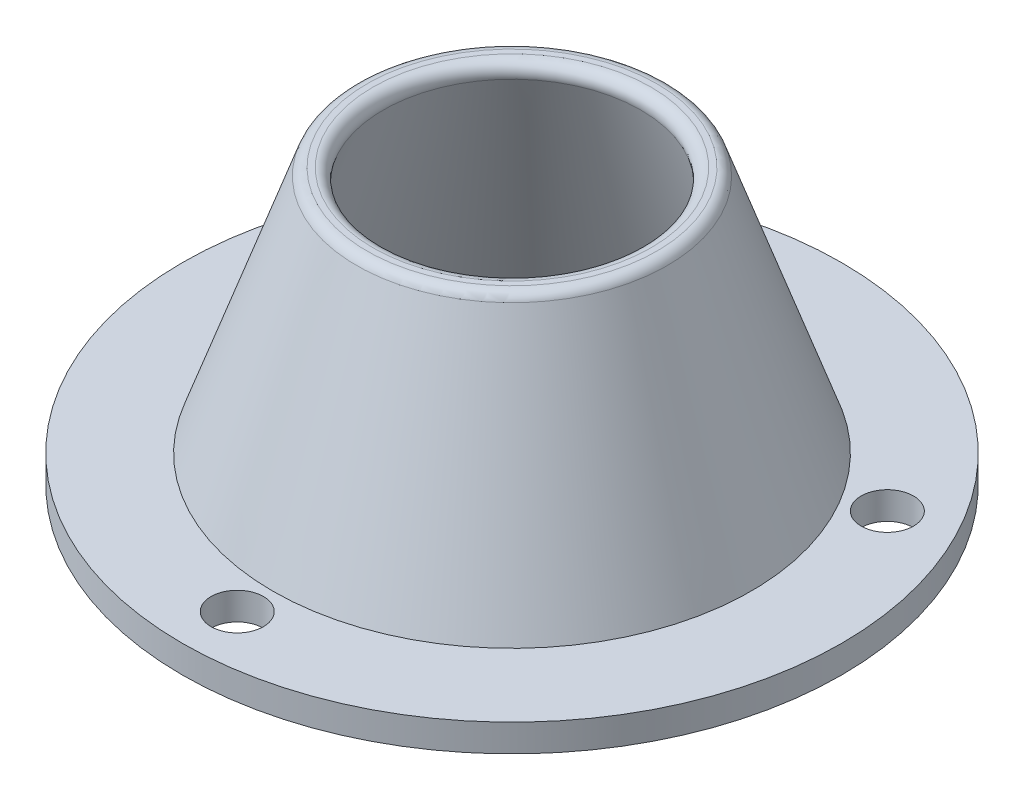
from build123d import *

# Parameters (mm, degrees)
CROQUIS3_R            = 4.7625
CORTAR_EXTRUIR2_DEPTH = 10


with BuildPart() as part:
    # Croquis2 → Revolución1 (revolve)
    with BuildSketch(Plane.XY):
        with BuildLine():
            Line((40, 0), (60, 0))
            Line((60, 0), (60, 5))
            Line((60, 5), (43.547405025, 5))
            Line((43.547405025, 5), (28.266159728, 48.660700849))
            ThreePointArc((28.266159728, 48.660700849), (27.535723945, 49.631165488), (26.378443015, 50))
            Line((26.378443015, 50), (25.31896201, 50))
            ThreePointArc((25.31896201, 50), (23.687796522, 49.15728093), (23.431245297, 47.339299151))
            Line((23.431245297, 47.339299151), (40, 0))
        make_face()
    revolve(axis=Axis((0, 0, 0), (0, 1, 0)))

    # Croquis3 → Cortar-Extruir2 (cut)
    with BuildSketch(Plane.XZ):
        with Locations((0, 50)):
            Circle(CROQUIS3_R)
        with Locations((43.301270189, -25)):
            Circle(CROQUIS3_R)
        with Locations((-43.301270189, -25)):
            Circle(CROQUIS3_R)
    extrude(amount=-CORTAR_EXTRUIR2_DEPTH, mode=Mode.SUBTRACT)


solid = part.part
